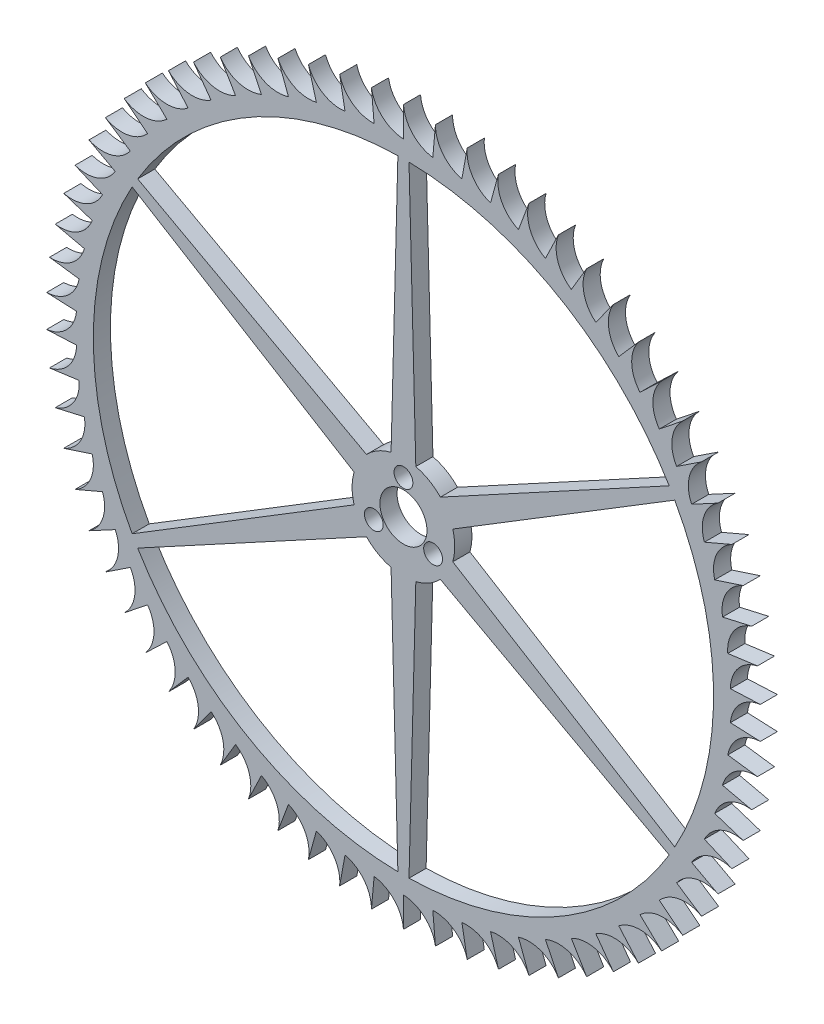
from build123d import *

# Parameters (mm, degrees)
SKETCH1_R            = 38.25
SKETCH1_R_2          = 36.25
BOSS_EXTRUDE1_DEPTH  = 2
CIRPATTERN1_COUNT    = 70
BOSS_EXTRUDE2_DEPTH  = 2
CIRPATTERN3_COUNT    = 6
M2_CLEARANCE_HOLE1_D = 2.2
SKETCH6_R            = 2.75
CUT_EXTRUDE1_DEPTH   = 3


with BuildPart() as part:
    # Sketch1 → Boss-Extrude1 (new body)
    with BuildSketch(Plane.XY):
        with BuildLine():
            Line((-27.5, 101.74791663), (-27.5, 98.24791663))
            ThreePointArc((-27.5, 98.24791663), (-25.692825348, 98.205201535), (-23.889686965, 98.077151652))
            ThreePointArc((-23.889686965, 98.077151652), (-26.363950048, 99.254446748), (-27.5, 101.74791663))
        make_face()
        with Locations((-27.5, 59.99791663)):
            Circle(SKETCH1_R)
        with Locations((-27.5, 59.99791663)):
            Circle(SKETCH1_R_2, mode=Mode.SUBTRACT)
    boss_extrude1 = extrude(amount=-BOSS_EXTRUDE1_DEPTH)

    # CirPattern1: Boss-Extrude1 ×70 about axis
    cirpattern1_axis = Axis((-27.5, 59.99791663, 0), (0, 0, 1))
    for i in range(1, CIRPATTERN1_COUNT):
        add(boss_extrude1.rotate(cirpattern1_axis, i * 360 / CIRPATTERN1_COUNT))

    # Sketch2 → Boss-Extrude2 (add)
    with BuildSketch(Plane.XY):
        with BuildLine():
            Line((-26.85, 96.24791663), (-28.15, 96.24791663))
            Line((-28.15, 96.24791663), (-28.946760033, 65.820878541))
            ThreePointArc((-28.946760033, 65.820878541), (-27.5, 53.99791663), (-26.053239967, 65.820878541))
            Line((-26.053239967, 65.820878541), (-26.85, 96.24791663))
        make_face()
    boss_extrude2 = extrude(amount=-BOSS_EXTRUDE2_DEPTH)

    # CirPattern3: Boss-Extrude2 ×6 about axis
    cirpattern3_axis = Axis((-27.5, 59.99791663, 0), (0, 0, 1))
    for i in range(1, CIRPATTERN3_COUNT):
        add(boss_extrude2.rotate(cirpattern3_axis, i * 360 / CIRPATTERN3_COUNT))

    # M2 Clearance Hole1 (through all)
    with Locations(Plane.XY):
        with Locations((-27.5, 63.99791663), (-30.964101615, 57.99791663), (-24.035898385, 57.99791663)):
            Hole(M2_CLEARANCE_HOLE1_D / 2)

    # Sketch6 → Cut-Extrude1 (cut, through all)
    with BuildSketch(Plane.XY):
        with Locations((-27.5, 59.99791663)):
            Circle(SKETCH6_R)
    extrude(amount=-CUT_EXTRUDE1_DEPTH, mode=Mode.SUBTRACT)


solid = part.part
